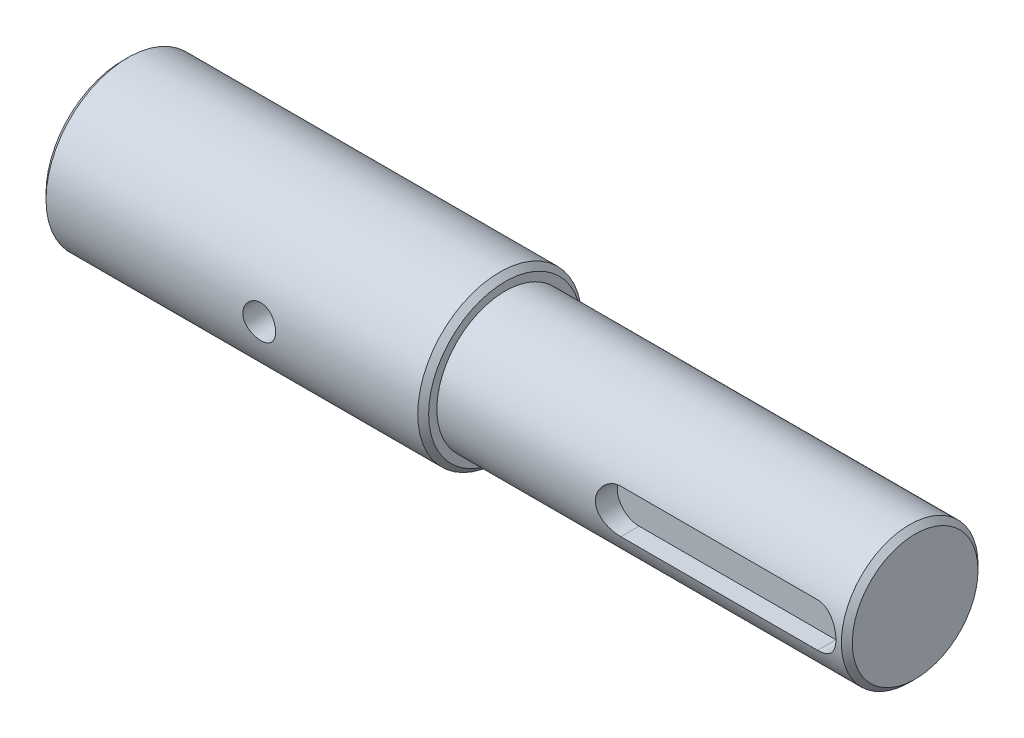
from build123d import *

# Parameters (mm, degrees)
SKETCH_1_R               = 12.5
EXTRUDE_1_DEPTH          = 75
SKETCH_2_R               = 15
EXTRUDE_2_DEPTH          = 70
CHAMFER_1_SIZE           = 1
CUT_EXTRUDE_1_DEPTH      = 4
SKETCH_4_R               = 3
CUT_EXTRUDE_2_DEPTH      = 16
CUT_EXTRUDE_2_DEPTH_BACK = 16


with BuildPart() as part:
    # 草图1 → 凸台-拉伸1 (new body)
    with BuildSketch(Plane(origin=(0, 0, 0), x_dir=(0, 0, -1), z_dir=(1, 0, 0))):
        Circle(SKETCH_1_R)
    extrude(amount=EXTRUDE_1_DEPTH)

    # 草图2 → 凸台-拉伸2 (add)
    with BuildSketch(Plane.ZY):
        Circle(SKETCH_2_R)
    extrude(amount=EXTRUDE_2_DEPTH)

    # 倒角1
    chamfer_1_edges = [part.edges().sort_by_distance(p)[0] for p in [
        (75, 0, 12.5),
        (0, 0, -15),
        (-70, 0, -15),
    ]]
    chamfer(chamfer_1_edges, length=CHAMFER_1_SIZE)

    # 草图3 → 切除-拉伸1 (cut)
    with BuildSketch(Plane.XY.offset(12.5)):
        with BuildLine():
            Line((32.999999837, 4), (68.999998276, 4))
            ThreePointArc((68.999998276, 4), (73, 5.01e-07), (68.999999277, -4))
            Line((68.999999277, -4), (33.000000086, -4))
            ThreePointArc((33.000000086, -4), (29, -1.25e-07), (32.999999837, 4))
        make_face()
    extrude(amount=-CUT_EXTRUDE_1_DEPTH, mode=Mode.SUBTRACT)

    # 草图4 → 切除-拉伸2 (cut, two sides)
    with BuildSketch(Plane.XY) as cut_extrude_2_sk:
        with Locations((-30, 0)):
            Circle(SKETCH_4_R)
    extrude(amount=CUT_EXTRUDE_2_DEPTH, mode=Mode.SUBTRACT)
    extrude(cut_extrude_2_sk.sketch, amount=-CUT_EXTRUDE_2_DEPTH_BACK, mode=Mode.SUBTRACT)


solid = part.part
